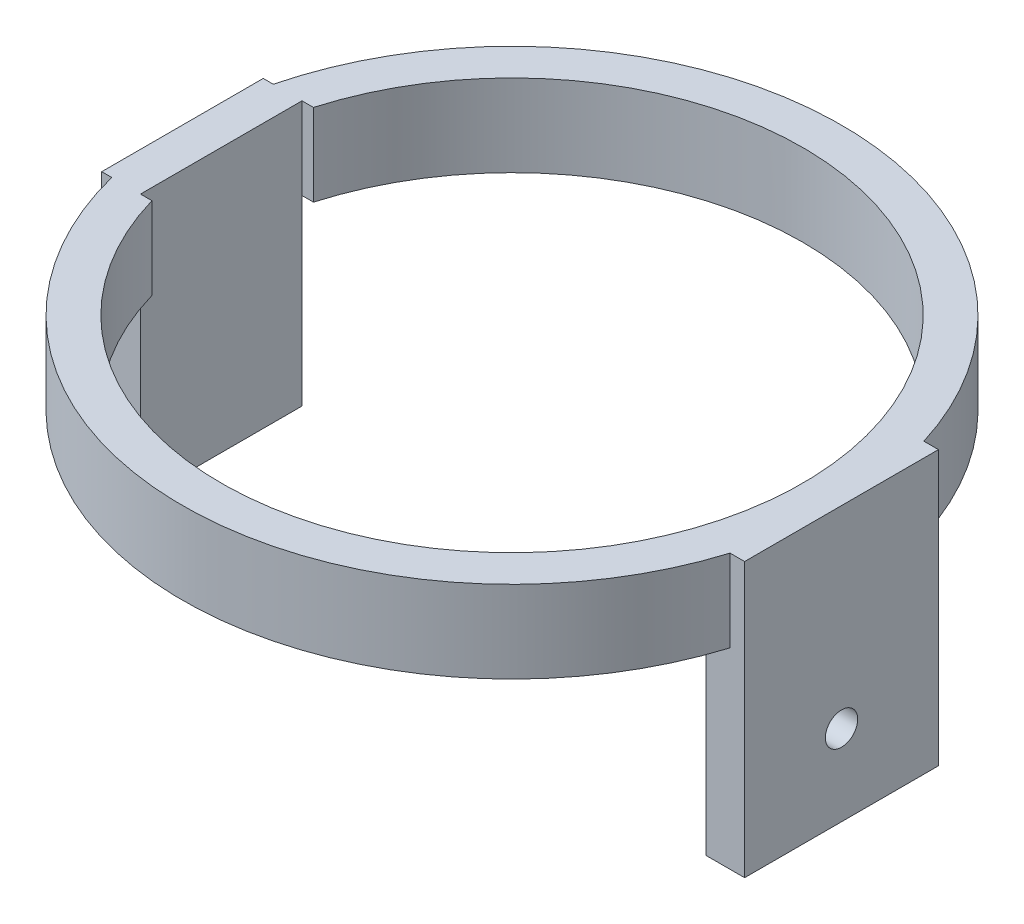
from build123d import *

# Parameters (mm, degrees)
SKETCH1_R                = 102
SKETCH1_R_2              = 90
BOSS_EXTRUDE1_DEPTH      = 25.4
BOSS_EXTRUDE4_DEPTH      = 12
SKETCH14_W               = 3.541917671
SKETCH14_H               = 50
CUT_EXTRUDE2_DEPTH       = 25.4
SKETCH8_W                = 60
SKETCH8_H                = 84.7705
BOSS_EXTRUDE5_DEPTH      = 12
M8_CLEARANCE_HOLE1_D     = 10
M8_CLEARANCE_HOLE1_DEPTH = 12


with BuildPart() as part:
    # Sketch1 → Boss-Extrude1 (new body)
    with BuildSketch(Plane(origin=(0, 0, 0), x_dir=(1, 0, 0), z_dir=(0, 1, 0))):
        Circle(SKETCH1_R)
        Circle(SKETCH1_R_2, mode=Mode.SUBTRACT)
    extrude(amount=-BOSS_EXTRUDE1_DEPTH)

    # Sketch7 → Boss-Extrude4 (add)
    with BuildSketch(Plane(origin=(-90, 0, 0), x_dir=(0, 0, -1), z_dir=(1, 0, 0))):
        Polygon((-25, -25.4), (-25, -81.8336), (25, -81.8336), (25, -25.4), (25, 0), (-25, 0), align=None)
    extrude(amount=-BOSS_EXTRUDE4_DEPTH)

    # Sketch14 → Cut-Extrude2 (cut)
    with BuildSketch(Plane.XZ.offset(25.4)):
        with Locations((-88.229041165, 0)):
            Rectangle(SKETCH14_W, SKETCH14_H)
    extrude(amount=-CUT_EXTRUDE2_DEPTH, mode=Mode.SUBTRACT)

    # Sketch8 → Boss-Extrude5 (add)
    with BuildSketch(Plane.ZY.offset(-90)):
        with Locations((0, -42.38525)):
            Rectangle(SKETCH8_W, SKETCH8_H)
    extrude(amount=-BOSS_EXTRUDE5_DEPTH)

    # M8 Clearance Hole1
    with Locations(Plane.ZY.offset(-90)):
        with Locations((0, -59.7705)):
            Hole(M8_CLEARANCE_HOLE1_D / 2, depth=M8_CLEARANCE_HOLE1_DEPTH)


solid = part.part
